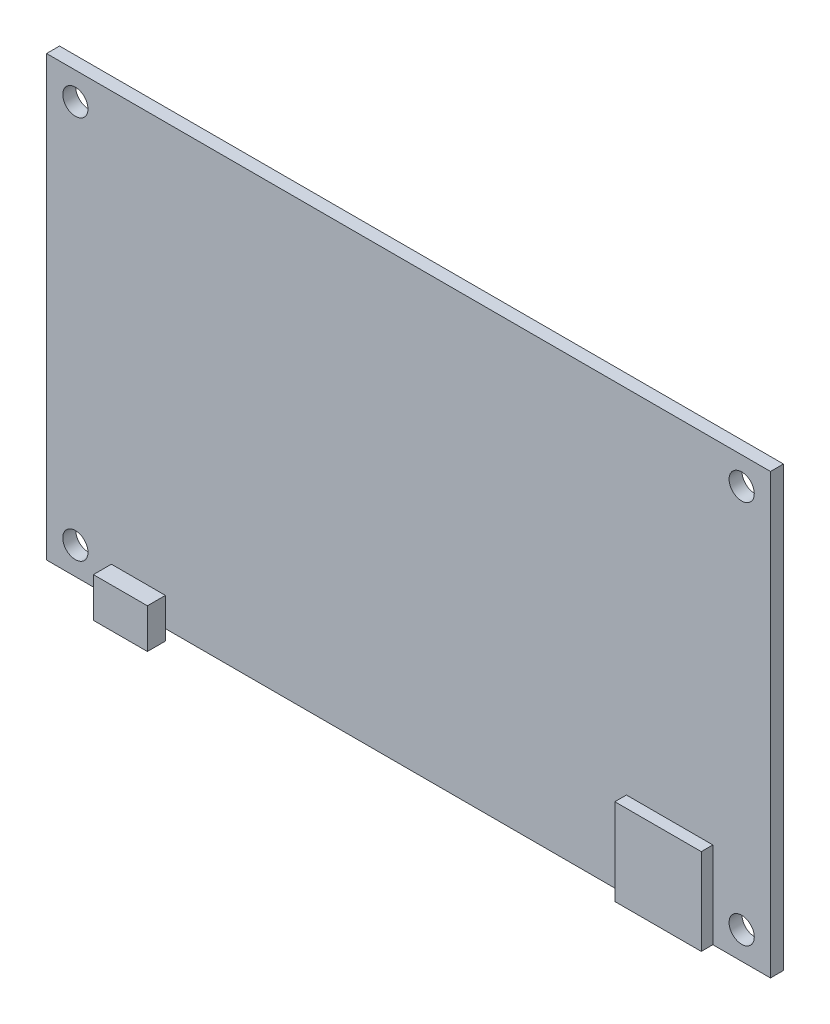
from build123d import *

# Parameters (mm, degrees)
SKETCH1_W           = 100.5
SKETCH1_H           = 60.9
BOSS_EXTRUDE1_DEPTH = 1.8
SKETCH2_R           = 1.75
CUT_EXTRUDE1_DEPTH  = 1.8
SKETCH3_W           = 12
SKETCH3_H           = 12
BOSS_EXTRUDE2_DEPTH = 1.61
SKETCH4_W           = 7.5
SKETCH4_H           = 5.5
BOSS_EXTRUDE3_DEPTH = 2.5


with BuildPart() as part:
    # Sketch1 → Boss-Extrude1 (new body)
    with BuildSketch(Plane.XY):
        with Locations((0, 30.45)):
            Rectangle(SKETCH1_W, SKETCH1_H)
    extrude(amount=BOSS_EXTRUDE1_DEPTH)

    # Sketch2 → Cut-Extrude1 (cut)
    with BuildSketch(Plane.XY.offset(1.8)):
        with Locations((-46.25, 3.8)):
            Circle(SKETCH2_R)
        with Locations((-46.25, 57.1)):
            Circle(SKETCH2_R)
    cut_extrude1 = extrude(amount=-CUT_EXTRUDE1_DEPTH, mode=Mode.SUBTRACT)

    # Mirror1: Cut-Extrude1 across plane
    add(cut_extrude1.mirror(Plane(origin=(0, 0, 0), x_dir=(0, 0, 1), z_dir=(1, 0, 0))), mode=Mode.SUBTRACT)

    # Sketch3 → Boss-Extrude2 (add)
    with BuildSketch(Plane.XY.offset(1.8)):
        with Locations((36.25, 6)):
            Rectangle(SKETCH3_W, SKETCH3_H)
    extrude(amount=BOSS_EXTRUDE2_DEPTH)

    # Sketch4 → Boss-Extrude3 (add)
    with BuildSketch(Plane.XY.offset(1.8)):
        with Locations((-37.5, 1.25)):
            Rectangle(SKETCH4_W, SKETCH4_H)
    extrude(amount=BOSS_EXTRUDE3_DEPTH)


solid = part.part
